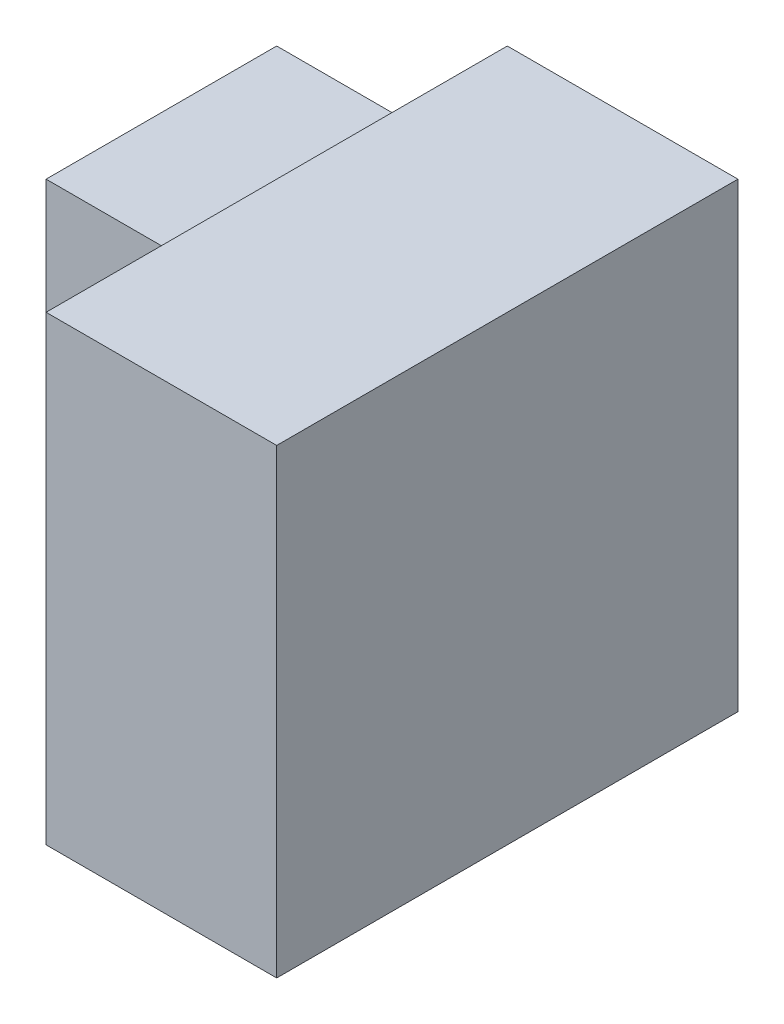
from build123d import *

# Parameters (mm, degrees)
SKETCH1_W           = 4
SKETCH1_H           = 4
BOSS_EXTRUDE1_DEPTH = 2
SKETCH2_W           = 2
SKETCH2_H           = 3
BOSS_EXTRUDE2_DEPTH = 2


with BuildPart() as part:
    # Sketch1 → Boss-Extrude1 (new body)
    with BuildSketch(Plane(origin=(0, 0, 0), x_dir=(0, 0, -1), z_dir=(1, 0, 0))):
        with Locations((2, 2)):
            Rectangle(SKETCH1_W, SKETCH1_H)
    extrude(amount=BOSS_EXTRUDE1_DEPTH)

    # Sketch2 → Boss-Extrude2 (add)
    with BuildSketch(Plane.ZY):
        with Locations((-3, 1.5)):
            Rectangle(SKETCH2_W, SKETCH2_H)
    extrude(amount=BOSS_EXTRUDE2_DEPTH)


solid = part.part
